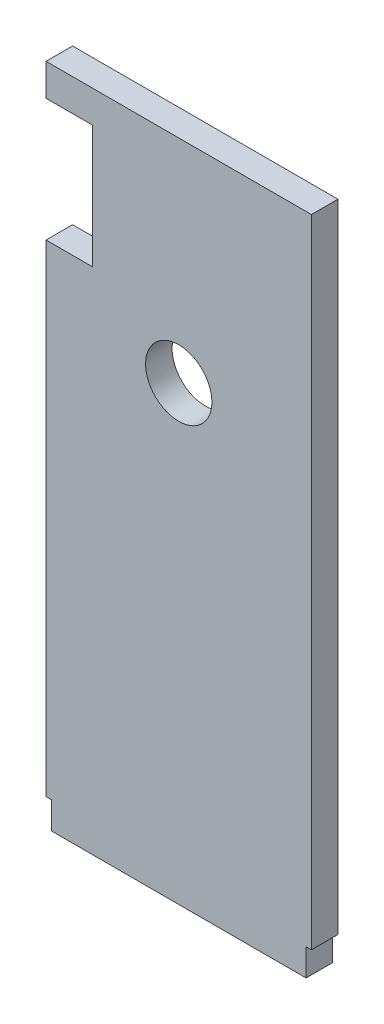
from build123d import *

# Parameters (mm, degrees)
SKETCH2_R           = 7.9375
BOSS_EXTRUDE1_DEPTH = 6.35
SKETCH3_W           = 1.27
SKETCH3_H           = 6.477
CUT_EXTRUDE1_DEPTH  = 7.35


with BuildPart() as part:
    # Sketch2 → Boss-Extrude1 (new body)
    with BuildSketch(Plane.XY):
        Polygon((0, 0), (63.5, 0), (63.5, 158.877), (0, 158.877), (0, 151.2062), (11.0998, 151.2062), (11.0998, 121.8438), (0, 121.8438), align=None)
        with Locations((31.75, 108.077)):
            Circle(SKETCH2_R, mode=Mode.SUBTRACT)
    extrude(amount=BOSS_EXTRUDE1_DEPTH)

    # Sketch3 → Cut-Extrude1 (cut, through all)
    with BuildSketch(Plane.XY.offset(6.35)):
        with Locations((0.635, 3.2385)):
            Rectangle(SKETCH3_W, SKETCH3_H)
        with Locations((62.865, 3.2385)):
            Rectangle(SKETCH3_W, SKETCH3_H)
    extrude(amount=-CUT_EXTRUDE1_DEPTH, mode=Mode.SUBTRACT)


solid = part.part
